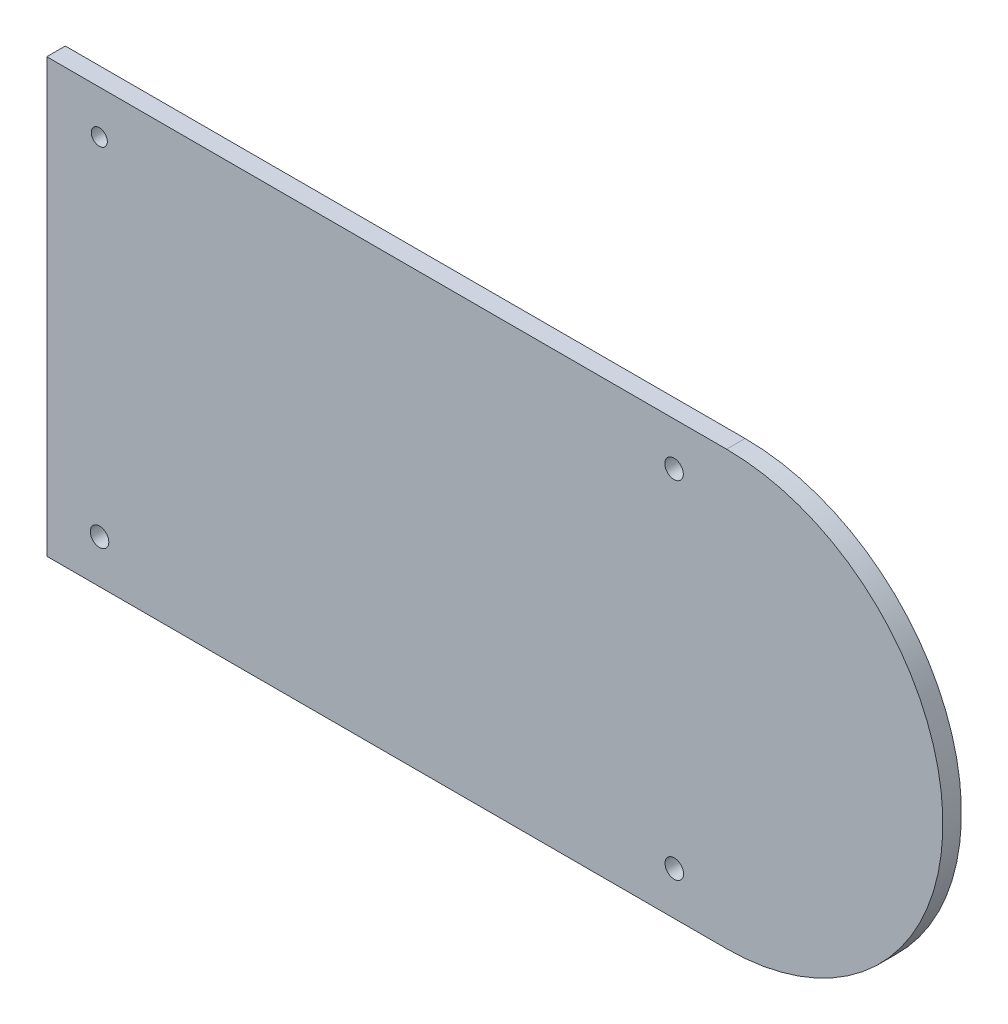
from build123d import *

# Parameters (mm, degrees)
SKETCH1_R           = 1.3
SKETCH1_R_2         = 1.5
BOSS_EXTRUDE1_DEPTH = 3


with BuildPart() as part:
    # Sketch1 → Boss-Extrude1 (new body)
    with BuildSketch(Plane.XY):
        with BuildLine():
            Line((-67.43171984, 21.978952762), (-67.43171984, -48.021047238))
            Line((-67.43171984, -48.021047238), (42.56828016, -48.021047238))
            ThreePointArc((42.56828016, -48.021047238), (77.56828016, -13.021047238), (42.56828016, 21.978952762))
            Line((42.56828016, 21.978952762), (-67.43171984, 21.978952762))
        make_face()
        with Locations((-58.93171984, 14.978952762)):
            Circle(SKETCH1_R, mode=Mode.SUBTRACT)
        with Locations((34.06828016, 14.978952762)):
            Circle(SKETCH1_R_2, mode=Mode.SUBTRACT)
        with Locations((34.104880448, -41.021035277)):
            Circle(SKETCH1_R_2, mode=Mode.SUBTRACT)
        with Locations((-58.895119552, -41.021035277)):
            Circle(SKETCH1_R_2, mode=Mode.SUBTRACT)
    extrude(amount=BOSS_EXTRUDE1_DEPTH)


solid = part.part
